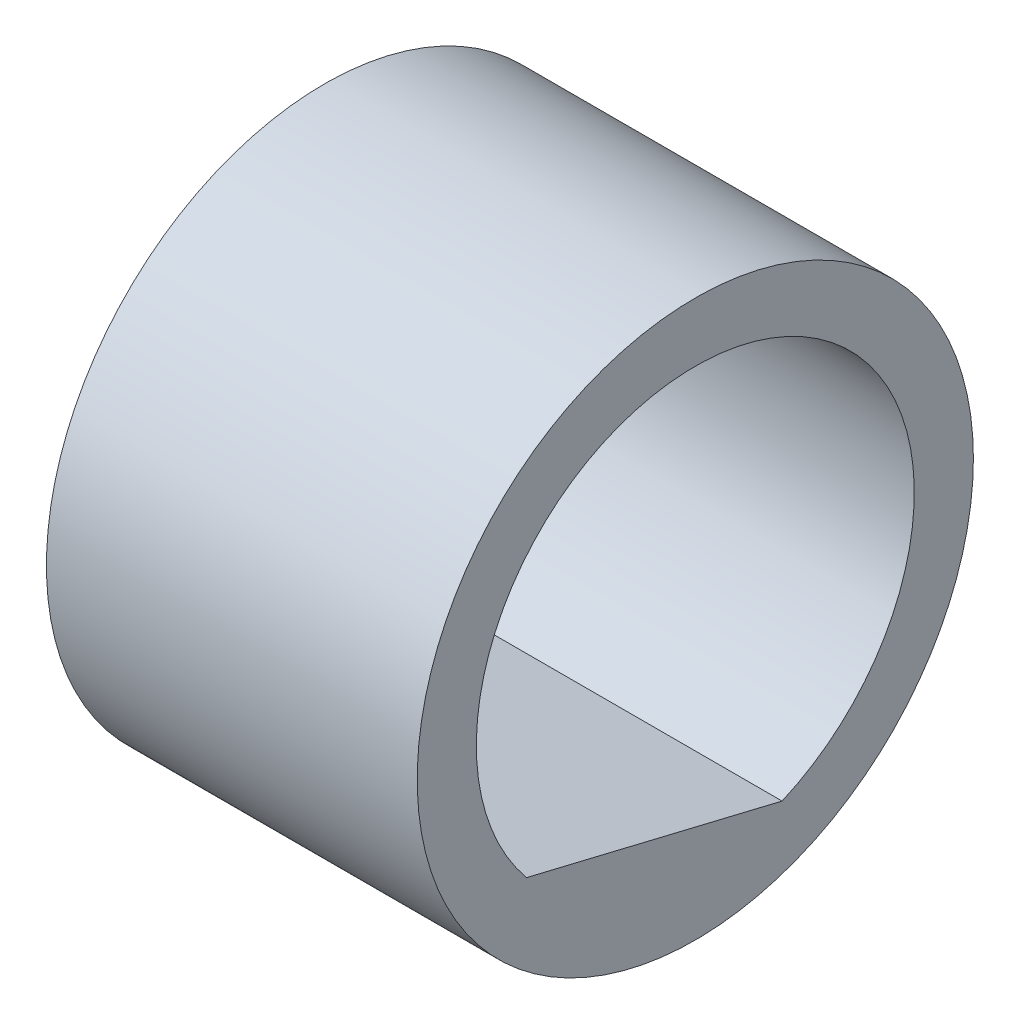
from build123d import *

# Parameters (mm, degrees)
SKETCH1_R           = 3.81
BOSS_EXTRUDE1_DEPTH = 5.08
CUT_EXTRUDE1_REACH  = 7.08


with BuildPart() as part:
    # Sketch1 → Boss-Extrude1 (new body)
    with BuildSketch(Plane(origin=(0, 0, 0), x_dir=(0, 0, -1), z_dir=(1, 0, 0))):
        Circle(SKETCH1_R)
    extrude(amount=BOSS_EXTRUDE1_DEPTH)

    # Sketch2 → Cut-Extrude1 (cut, up to next)
    with BuildSketch(Plane.ZY, mode=Mode.PRIVATE) as cut_extrude1_sk1:
        with BuildLine():
            Line((2.311324129, -1.912532554), (-1.188860496, -2.754380279))
            ThreePointArc((-1.188860496, -2.754380279), (-0.701539771, 2.916820521), (2.311324129, -1.912532554))
        make_face()
    cut_extrude1_tool1 = extrude(cut_extrude1_sk1.sketch, amount=-CUT_EXTRUDE1_REACH, mode=Mode.PRIVATE) & part.part
    add(cut_extrude1_tool1.solids().sort_by_distance((0, 0.141037, -0.033922))[0], mode=Mode.SUBTRACT)


solid = part.part
